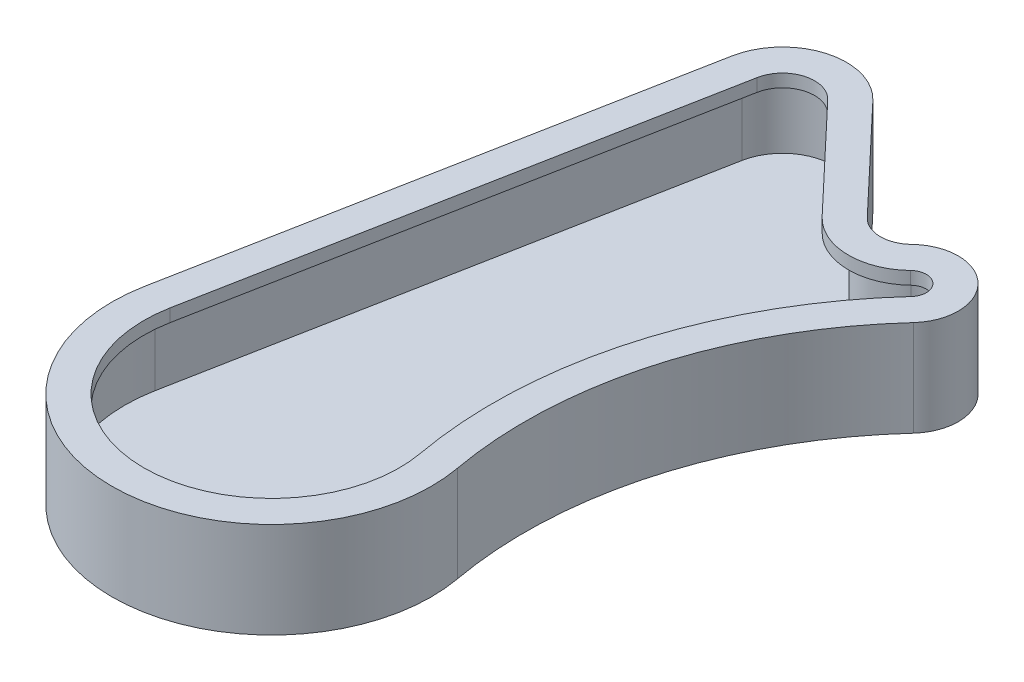
from build123d import *

# Parameters (mm, degrees)
BOSS_EXTRUDE2_DEPTH = 15
CUT_EXTRUDE1_DEPTH  = 13
BOSS_EXTRUDE3_DEPTH = 2


with BuildPart() as part:
    # Sketch1 → Boss-Extrude2 (new body)
    with BuildSketch(Plane(origin=(0, 0, 0), x_dir=(1, 0, 0), z_dir=(0, 1, 0))):
        with BuildLine():
            Line((-24.556615071, 4.6875), (-9.822646028, 81.875))
            ThreePointArc((-9.822646028, 81.875), (-2.807110947, 89.597923116), (7.264280872, 86.872424857))
            Line((7.264280872, 86.872424857), (22.693183777, 70.563787572))
            ThreePointArc((22.693183777, 70.563787572), (26.210044162, 69.001329126), (29.795194528, 70.4))
            ThreePointArc((29.795194528, 70.4), (40.230934436, 70.374693007), (40.539091673, 59.943473184))
            ThreePointArc((40.539091673, 59.943473184), (26.07415519, 34.077117396), (24.595709122, 4.477844661))
            ThreePointArc((24.595709122, 4.477844661), (-0.106634546, -24.99977258), (-24.556615071, 4.6875))
        make_face()
    extrude(amount=BOSS_EXTRUDE2_DEPTH)

    # Sketch2 → Cut-Extrude1 (cut)
    with BuildSketch(Plane(origin=(0, 15, 0), x_dir=(1, 0, 0), z_dir=(0, 1, 0))):
        with BuildLine():
            Line((21.240327603, 69.1893026), (5.811424698, 85.497939885))
            ThreePointArc((5.811424698, 85.497939885), (-2.245688757, 87.678338492), (-7.858116823, 81.5))
            Line((-7.858116823, 81.5), (-22.592085865, 4.3125))
            ThreePointArc((-22.592085865, 4.3125), (-0.098103783, -22.999790774), (22.628052392, 4.119617088))
            ThreePointArc((22.628052392, 4.119617088), (24.151989109, 34.629636676), (39.06200056, 61.291880335))
            ThreePointArc((39.06200056, 61.291880335), (38.836018587, 68.941441539), (31.183142654, 68.96))
            ThreePointArc((31.183142654, 68.96), (26.163932142, 67.001860776), (21.240327603, 69.1893026))
        make_face()
    extrude(amount=-CUT_EXTRUDE1_DEPTH, mode=Mode.SUBTRACT)

    # Sketch3 → Boss-Extrude3 (add)
    with BuildSketch(Plane(origin=(0, 15, 0), x_dir=(1, 0, 0), z_dir=(0, 1, 0))):
        with BuildLine():
            Line((22.693183777, 70.563787572), (7.264280872, 86.872424857))
            ThreePointArc((7.264280872, 86.872424857), (-2.807110947, 89.597923116), (-9.822646028, 81.875))
            Line((-9.822646028, 81.875), (-24.556615071, 4.6875))
            ThreePointArc((-24.556615071, 4.6875), (-0.106634546, -24.99977258), (24.595709122, 4.477844661))
            ThreePointArc((24.595709122, 4.477844661), (26.07415519, 34.077117396), (40.539091673, 59.943473184))
            ThreePointArc((40.539091673, 59.943473184), (40.230934436, 70.374693007), (29.795194528, 70.4))
            ThreePointArc((29.795194528, 70.4), (26.210044162, 69.001329126), (22.693183777, 70.563787572))
        make_face()
        with BuildLine():
            Line((19.061043341, 67.127575143), (3.632140436, 83.436212428))
            ThreePointArc((3.632140436, 83.436212428), (-1.403555473, 84.798961558), (-4.911323014, 80.9375))
            Line((-4.911323014, 80.9375), (-19.645292057, 3.75))
            ThreePointArc((-19.645292057, 3.75), (-0.085307637, -19.999818064), (19.676567297, 3.582275729))
            ThreePointArc((19.676567297, 3.582275729), (21.268739987, 35.458415597), (36.846363891, 63.314491061))
            ThreePointArc((36.846363891, 63.314491061), (36.743644812, 66.791564336), (33.265064843, 66.8))
            ThreePointArc((33.265064843, 66.8), (26.094764111, 64.002658251), (19.061043341, 67.127575143))
        make_face(mode=Mode.SUBTRACT)
    extrude(amount=-BOSS_EXTRUDE3_DEPTH)


solid = part.part
